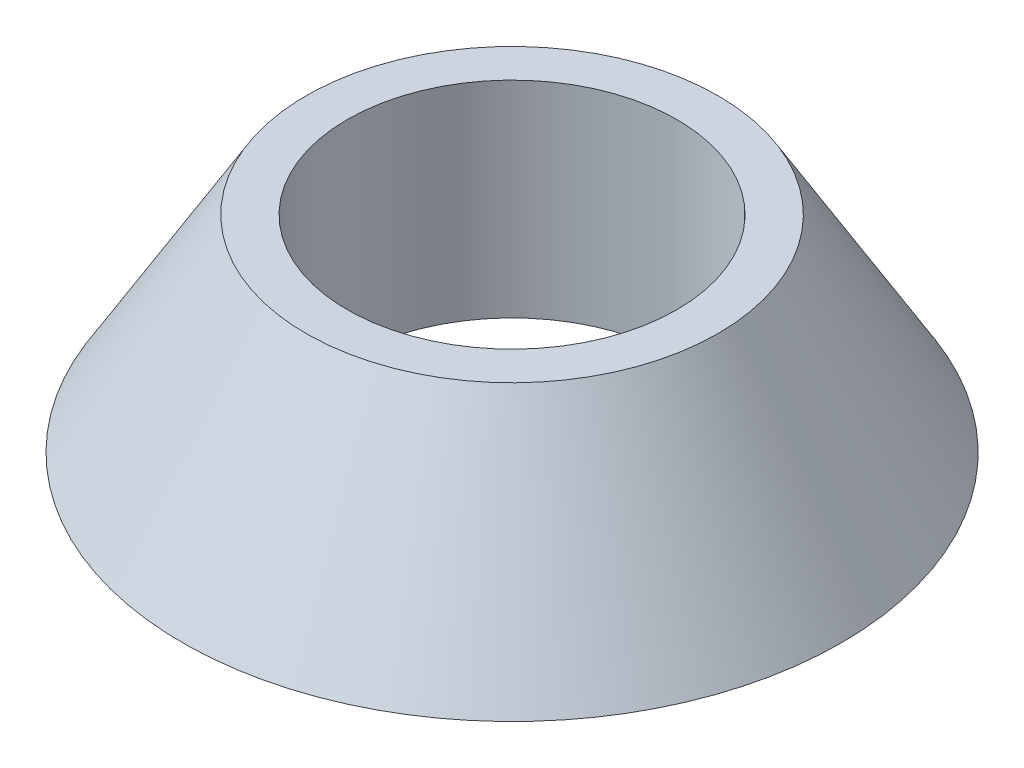
from build123d import *


with BuildPart() as part:
    # Szkic1 → Obrót1 (revolve)
    with BuildSketch(Plane.XY):
        Polygon((4, 0), (4, 5), (5, 5), (8, 0), align=None)
    revolve(axis=Axis((0, 0, 0), (0, 1, 0)))


solid = part.part
